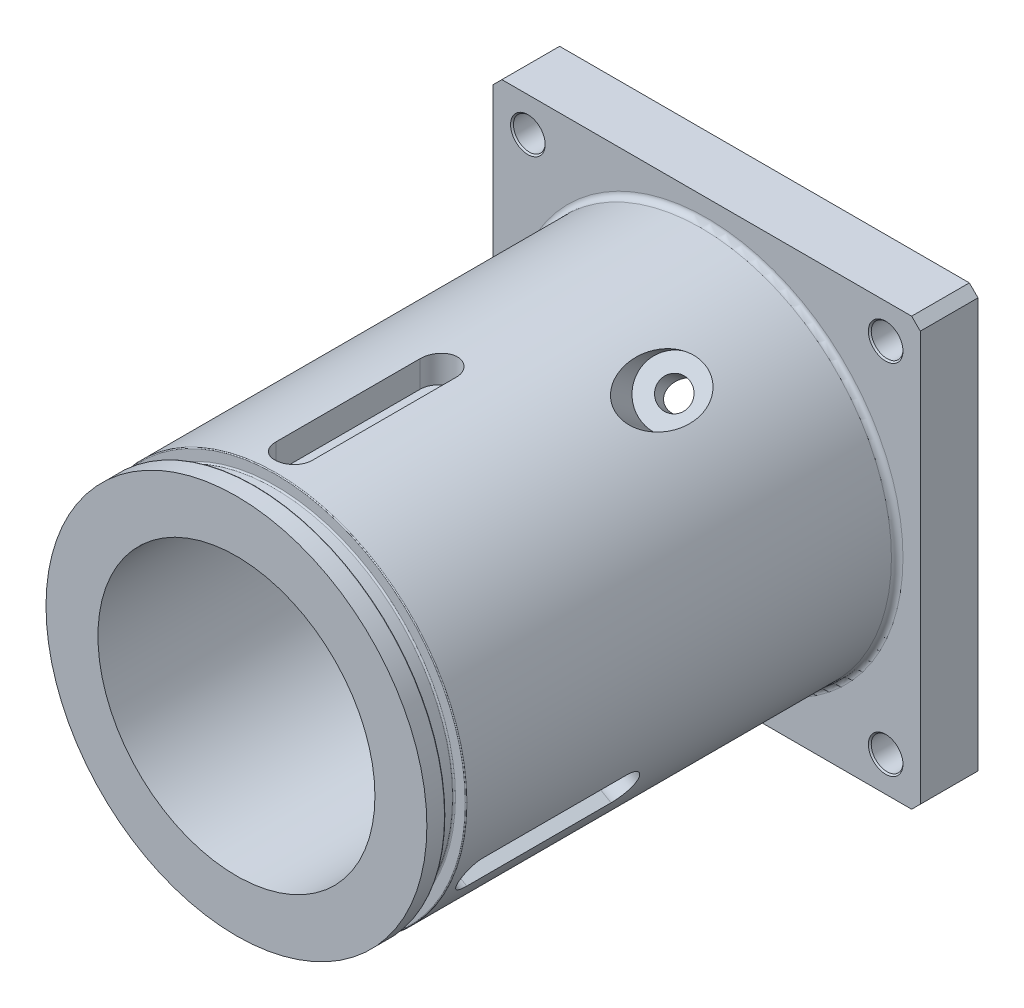
from build123d import *

# Parameters (mm, degrees)
ESBO_O1_W                        = 74
ESBO_O1_H                        = 74
RESSALTO_EXTRUS_O1_DEPTH         = 10
ESBO_O2_R                        = 33
ESBO_O2_R_2                      = 24
RESSALTO_EXTRUS_O2_DEPTH         = 81.5
ESBO_O3_R                        = 24
CORTE_EXTRUS_O1_DEPTH            = 11
FURO_COM_FOLGA_DE_M51_AT_2_COUNT = 2
FURO_COM_FOLGA_DE_M51_AT_2_PITCH = 62
FURO_COM_FOLGA_DE_M51_AT_3_COUNT = 2
FURO_COM_FOLGA_DE_M51_AT_3_PITCH = 87.681240867
FURO_COM_FOLGA_DE_M51_AT_4_COUNT = 2
FURO_COM_FOLGA_DE_M51_AT_4_PITCH = 62
ESBO_O12_W                       = 3.6
ESBO_O12_H                       = 2.1
FILETE1_R                        = 0.25
FILETE2_R                        = 0.15
PADR_OCIRCULAR2_COUNT            = 3
CHANFRO1_SIZE                    = 1.5
FILETE3_R                        = 1
CORTE_EXTRUS_O3_DEPTH            = 5
PADR_OCIRCULAR3_COUNT            = 3


with BuildPart() as part:
    # Esboço1 → Ressalto-extrusão1 (new body)
    with BuildSketch(Plane.XY):
        Rectangle(ESBO_O1_W, ESBO_O1_H)
    extrude(amount=RESSALTO_EXTRUS_O1_DEPTH)

    # Esboço2 → Ressalto-extrusão2 (add)
    with BuildSketch(Plane.XY.offset(10)):
        Circle(ESBO_O2_R)
        Circle(ESBO_O2_R_2, mode=Mode.SUBTRACT)
    extrude(amount=RESSALTO_EXTRUS_O2_DEPTH)

    # Esboço3 → Corte-extrusão1 (cut, through all)
    with BuildSketch(Plane.XY.offset(10)):
        Circle(ESBO_O3_R)
    extrude(amount=-CORTE_EXTRUS_O1_DEPTH, mode=Mode.SUBTRACT)

    # Esboço6 → Furo com folga de M51 (revolve, cut)
    with BuildSketch(Plane(origin=(31, 31, 0), x_dir=(0, 1, 0), z_dir=(1, 0, 0))):
        Polygon((0, 0), (0, 10), (3, 10), (2.75, 9.75), (2.75, 0.25), (3, 0), align=None)
    furo_com_folga_de_m51 = revolve(axis=Axis((31, 31, -6.35), (0, 0, 1)), mode=Mode.SUBTRACT)

    # Furo com folga de M51 at 2: Furo com folga de M51 ×2
    with Locations(*[(0, -i * FURO_COM_FOLGA_DE_M51_AT_2_PITCH, 0) for i in range(1, FURO_COM_FOLGA_DE_M51_AT_2_COUNT)]):
        add(furo_com_folga_de_m51, mode=Mode.SUBTRACT)

    # Furo com folga de M51 at 3: Furo com folga de M51 ×2
    with Locations(*[Vector(-0.707106781, -0.707106781, 0) * (i * FURO_COM_FOLGA_DE_M51_AT_3_PITCH) for i in range(1, FURO_COM_FOLGA_DE_M51_AT_3_COUNT)]):
        add(furo_com_folga_de_m51, mode=Mode.SUBTRACT)

    # Furo com folga de M51 at 4: Furo com folga de M51 ×2
    with Locations(*[(-i * FURO_COM_FOLGA_DE_M51_AT_4_PITCH, 0, 0) for i in range(1, FURO_COM_FOLGA_DE_M51_AT_4_COUNT)]):
        add(furo_com_folga_de_m51, mode=Mode.SUBTRACT)

    # Esboço12 → Corte-Revolução1 (revolve, cut)
    with BuildSketch(Plane(origin=(0, 0, 0), x_dir=(0, 0, -1), z_dir=(1, 0, 0))):
        with Locations((-86.5, 31.95)):
            Rectangle(ESBO_O12_W, ESBO_O12_H)
    revolve(axis=Axis((0, 0, 91.5), (0, 0, -1)), mode=Mode.SUBTRACT)

    # Filete1
    filete1_edges = [part.edges().sort_by_distance(p)[0] for p in [
        (0, -30.9, 88.3),
        (0, -30.9, 84.7),
    ]]
    fillet(filete1_edges, radius=FILETE1_R)

    # Filete2
    filete2_edges = [part.edges().sort_by_distance(p)[0] for p in [
        (-33, 0, 88.3),
        (-33, 0, 84.7),
    ]]
    fillet(filete2_edges, radius=FILETE2_R)

    # Esboço14 → Corte-Revolução2 (revolve, cut)
    with BuildSketch(Plane(origin=(0, 0, 0), x_dir=(1, 0, 0), z_dir=(0, 1, 0))):
        Polygon((-33.49041083, -34.849242405), (-18.641168425, -20), (-16.873401472, -21.767766953), (-26.772896409, -31.66726189), (-24.755663361, -33.684494937), (-33.49041083, -42.419242405), align=None)
    corte_revolu_o2 = revolve(axis=Axis((-33.49041083, 0, 34.849242405), (0.707106781, 0, -0.707106781)), mode=Mode.SUBTRACT)

    # PadrãoCircular2: Corte-Revolução2 ×3 about axis
    padr_ocircular2_axis = Axis((0, 0, 0), (0, 0, 1))
    for i in range(1, PADR_OCIRCULAR2_COUNT):
        add(corte_revolu_o2.rotate(padr_ocircular2_axis, i * 360 / PADR_OCIRCULAR2_COUNT), mode=Mode.SUBTRACT)

    # Chanfro1
    chanfro1_edges = [part.edges().sort_by_distance(p)[0] for p in [
        (-37, 37, 5),
        (37, 37, 5),
        (37, -37, 5),
        (-37, -37, 5),
    ]]
    chamfer(chanfro1_edges, length=CHANFRO1_SIZE)

    # Filete3
    filete3_edges = [part.edges().sort_by_distance(p)[0] for p in [
        (-33, 0, 10),
    ]]
    fillet(filete3_edges, radius=FILETE3_R)

    # Esboço15 → Corte-extrusão3 (cut)
    with BuildSketch(Plane(origin=(0, 33, 0), x_dir=(1, 0, 0), z_dir=(0, 1, 0))):
        with BuildLine():
            Line((-5.113748287, -79.55), (-5.113748287, -54.55))
            ThreePointArc((-5.113748287, -54.55), (-1.963748287, -51.4), (1.186251713, -54.55))
            Line((1.186251713, -54.55), (1.186251713, -79.55))
            ThreePointArc((1.186251713, -79.55), (-1.963748287, -82.7), (-5.113748287, -79.55))
        make_face()
    corte_extrus_o3 = extrude(amount=-CORTE_EXTRUS_O3_DEPTH, mode=Mode.SUBTRACT)

    # PadrãoCircular3: Corte-extrusão3 ×3 about axis
    padr_ocircular3_axis = Axis((0, 0, 0), (0, 0, 1))
    for i in range(1, PADR_OCIRCULAR3_COUNT):
        add(corte_extrus_o3.rotate(padr_ocircular3_axis, i * 360 / PADR_OCIRCULAR3_COUNT), mode=Mode.SUBTRACT)


solid = part.part
